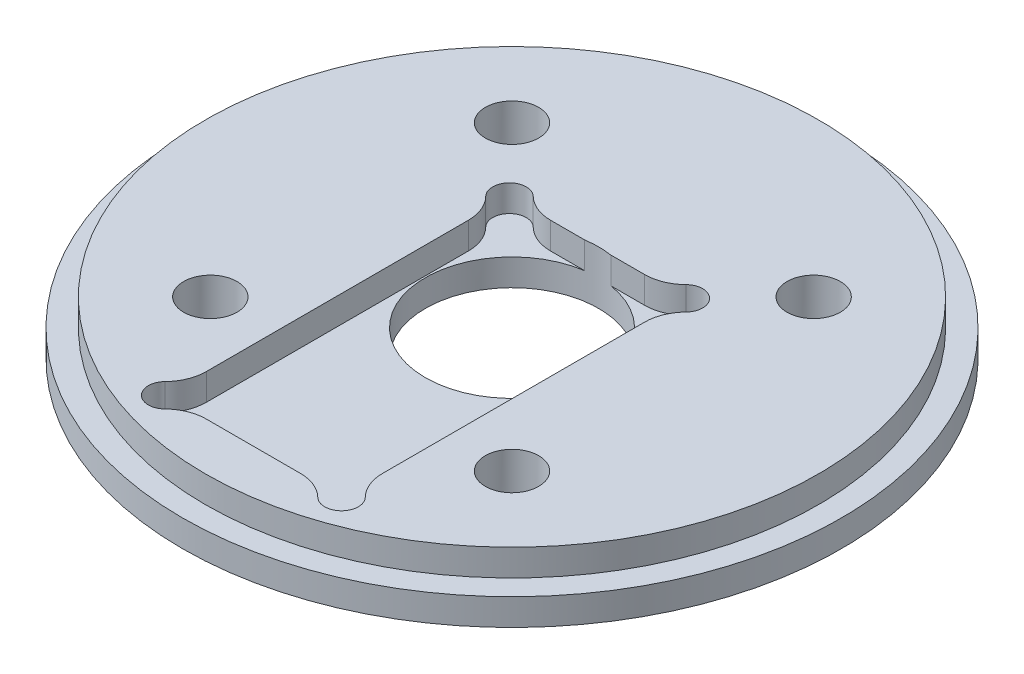
from build123d import *

# Parameters (mm, degrees)
SKETCH2_R                       = 39.243
BOSS_EXTRUDE1_DEPTH             = 6.35
SKETCH4_R                       = 39.243
SKETCH4_R_2                     = 36.5125
CUT_EXTRUDE1_DEPTH              = 3.175
F_1_4_0_25_DIAMETER_HOLE1_D     = 6.35
F_13_16_0_8125_DIAMETER_HOLE1_D = 20.6375
CUT_EXTRUDE3_DEPTH              = 3.175
SKETCH9_R                       = 6.0325
CUT_EXTRUDE2_DEPTH              = 1.5875


with BuildPart() as part:
    # Sketch2 → Boss-Extrude1 (new body)
    with BuildSketch(Plane(origin=(0, 0, 0), x_dir=(1, 0, 0), z_dir=(0, 1, 0))):
        Circle(SKETCH2_R)
    extrude(amount=BOSS_EXTRUDE1_DEPTH)

    # Sketch4 → Cut-Extrude1 (cut)
    with BuildSketch(Plane(origin=(0, 6.35, 0), x_dir=(1, 0, 0), z_dir=(0, 1, 0))):
        Circle(SKETCH4_R)
        Circle(SKETCH4_R_2, mode=Mode.SUBTRACT)
    extrude(amount=-CUT_EXTRUDE1_DEPTH, mode=Mode.SUBTRACT)

    # 1/4 (0.25) Diameter Hole1 (through all)
    with Locations(Plane(origin=(0, 6.35, 0), x_dir=(1, 0, 0), z_dir=(0, 1, 0))):
        with Locations((-17.960512242, 17.960512242), (-17.960512242, -17.960512242), (17.960512242, 17.960512242), (17.960512242, -17.960512242)):
            Hole(F_1_4_0_25_DIAMETER_HOLE1_D / 2)

    # 13/16 (0.8125) Diameter Hole1 (through all)
    with Locations(Plane(origin=(0, 6.35, 0), x_dir=(1, 0, 0), z_dir=(0, 1, 0))):
        with Locations((0, 0)):
            Hole(F_13_16_0_8125_DIAMETER_HOLE1_D / 2)

    # Sketch11 → Cut-Extrude3 (cut)
    with BuildSketch(Plane(origin=(0, 6.35, 0), x_dir=(1, 0, 0), z_dir=(0, 1, 0))):
        with BuildLine():
            Line((-5.601020514, 10.2), (5.601020514, 10.2))
            ThreePointArc((5.601020514, 10.2), (7.490842879, 10.570899501), (9.100291576, 11.628571429))
            ThreePointArc((9.100291576, 11.628571429), (11.914213562, 11.614213562), (11.928571429, 8.800291576))
            ThreePointArc((11.928571429, 8.800291576), (10.870899501, 7.190842879), (10.5, 5.301020514))
            Line((10.5, 5.301020514), (10.5, -25.901020514))
            ThreePointArc((10.5, -25.901020514), (10.870899501, -27.790842879), (11.928571429, -29.400291576))
            ThreePointArc((11.928571429, -29.400291576), (11.914213562, -32.214213562), (9.100291576, -32.228571429))
            ThreePointArc((9.100291576, -32.228571429), (7.490842879, -31.170899501), (5.601020514, -30.8))
            Line((5.601020514, -30.8), (-5.601020514, -30.8))
            ThreePointArc((-5.601020514, -30.8), (-7.490842879, -31.170899501), (-9.100291576, -32.228571429))
            ThreePointArc((-9.100291576, -32.228571429), (-11.914213562, -32.214213562), (-11.928571429, -29.400291576))
            ThreePointArc((-11.928571429, -29.400291576), (-10.870899501, -27.790842879), (-10.5, -25.901020514))
            Line((-10.5, -25.901020514), (-10.5, 5.301020514))
            ThreePointArc((-10.5, 5.301020514), (-10.870899501, 7.190842879), (-11.928571429, 8.800291576))
            ThreePointArc((-11.928571429, 8.800291576), (-11.914213562, 11.614213562), (-9.100291576, 11.628571429))
            ThreePointArc((-9.100291576, 11.628571429), (-7.490842879, 10.570899501), (-5.601020514, 10.2))
        make_face()
    extrude(amount=-CUT_EXTRUDE3_DEPTH, mode=Mode.SUBTRACT)

    # Sketch9 → Cut-Extrude2 (cut)
    with BuildSketch(Plane.XZ):
        with Locations((-17.960512242, 17.960512242)):
            Circle(SKETCH9_R)
        with Locations((17.960512242, 17.960512242)):
            Circle(SKETCH9_R)
        with Locations((17.960512242, -17.960512242)):
            Circle(SKETCH9_R)
        with Locations((-17.960512242, -17.960512242)):
            Circle(SKETCH9_R)
    extrude(amount=-CUT_EXTRUDE2_DEPTH, mode=Mode.SUBTRACT)


solid = part.part
